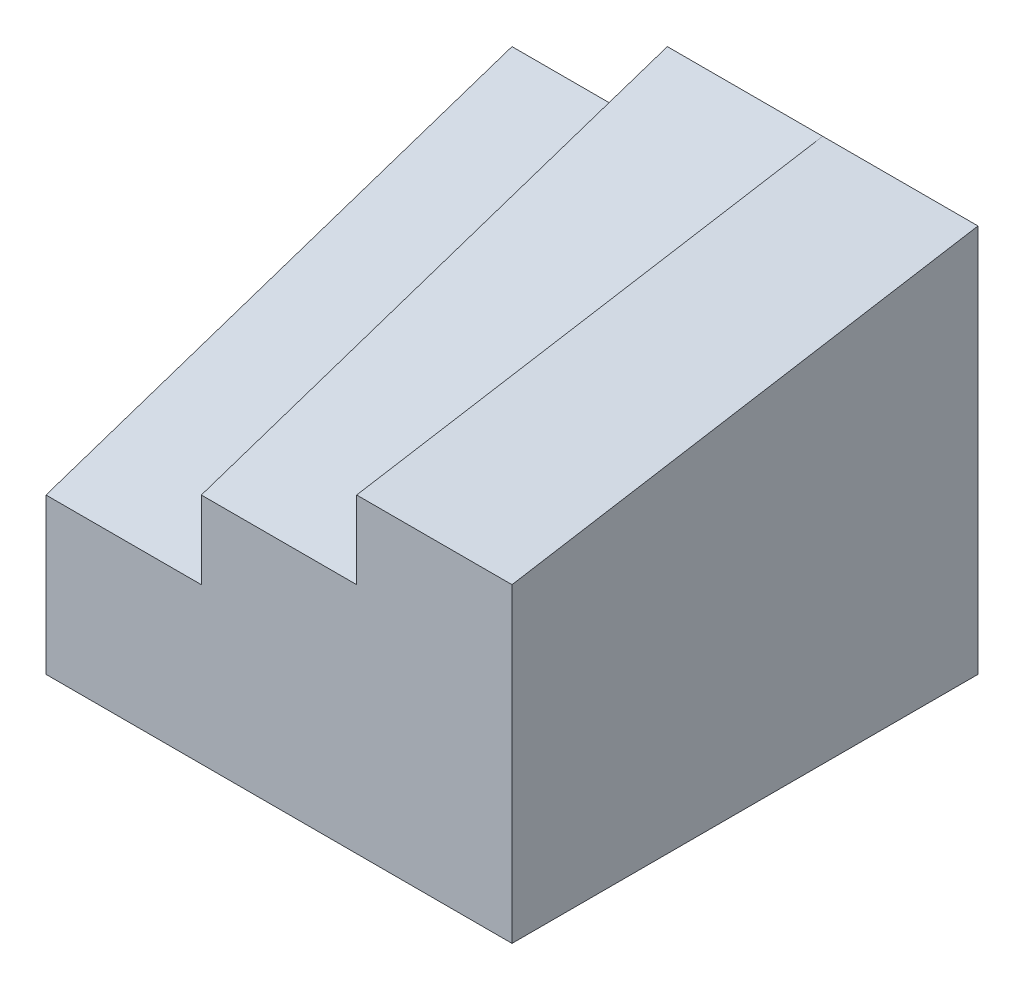
from build123d import *

# Parameters (mm, degrees)
SKETCH1_W           = 6
SKETCH1_H           = 6
BOSS_EXTRUDE1_DEPTH = 5
CUT_EXTRUDE1_DEPTH  = 1
CUT_EXTRUDE2_DEPTH  = 2
CUT_EXTRUDE3_DEPTH  = 2


with BuildPart() as part:
    # Sketch1 → Boss-Extrude1 (new body)
    with BuildSketch(Plane(origin=(0, 0, 0), x_dir=(1, 0, 0), z_dir=(0, 1, 0))):
        Rectangle(SKETCH1_W, SKETCH1_H)
    extrude(amount=BOSS_EXTRUDE1_DEPTH)

    # Sketch2 → Cut-Extrude1 (cut, symmetric)
    with BuildSketch(Plane(origin=(0, 0, 0), x_dir=(0, 0, -1), z_dir=(1, 0, 0))):
        Polygon((-3, 0), (3, 0), (3, 1), align=None)
        Polygon((3, 5), (-3, 5), (-3, 3), align=None)
    extrude(amount=CUT_EXTRUDE1_DEPTH, both=True, mode=Mode.SUBTRACT)

    # Sketch3 → Cut-Extrude2 (cut)
    with BuildSketch(Plane.ZY.offset(3)):
        Polygon((-3, 4), (3, 2), (3, 5), (-3, 5), align=None)
    extrude(amount=-CUT_EXTRUDE2_DEPTH, mode=Mode.SUBTRACT)

    # Sketch4 → Cut-Extrude3 (cut)
    with BuildSketch(Plane.ZY.offset(-1)):
        Polygon((3, 5), (-3, 5), (3, 4), align=None)
    extrude(amount=-CUT_EXTRUDE3_DEPTH, mode=Mode.SUBTRACT)


solid = part.part
